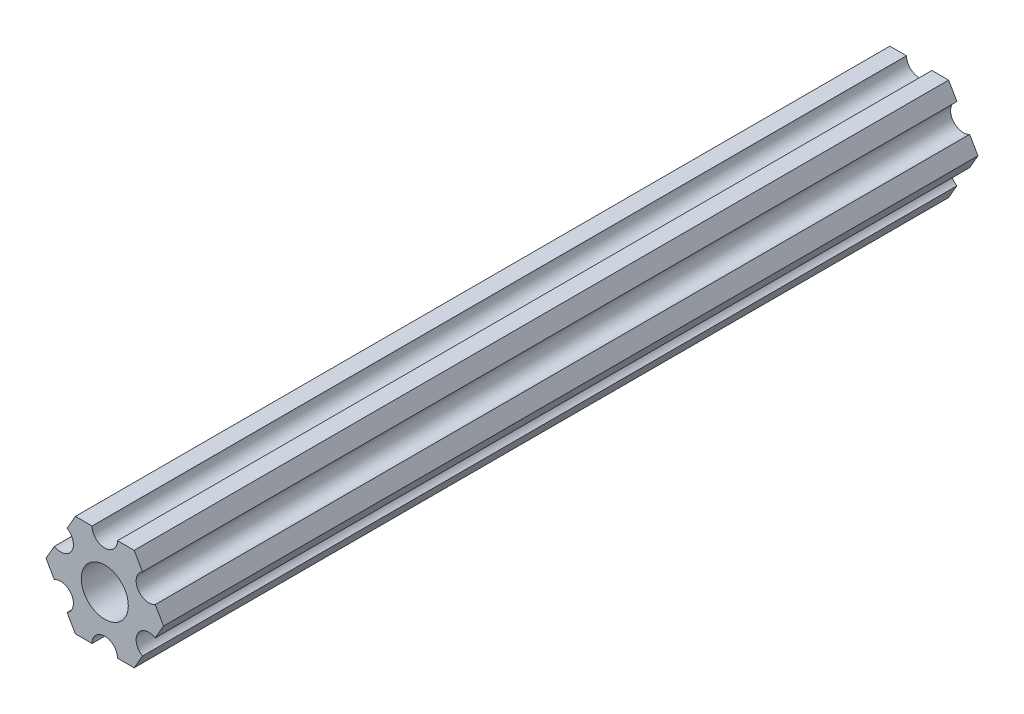
from build123d import *

# Parameters (mm, degrees)
SKETCH1_R           = 2.9337
BOSS_EXTRUDE1_DEPTH = 101.6


with BuildPart() as part:
    # Sketch1 → Boss-Extrude1 (new body)
    with BuildSketch(Plane.XY):
        with BuildLine():
            Line((-1.587500385, 6.349999904), (-3.666174594, 6.349999778))
            Line((-3.666174594, 6.349999778), (-4.70551159, 4.549815043))
            ThreePointArc((-4.70551159, 4.549815043), (-4.12444613, 2.38124975), (-6.293011423, 1.80018429))
            Line((-6.293011423, 1.80018429), (-7.332348419, -4.44e-07))
            Line((-7.332348419, -4.44e-07), (-6.293011205, -1.800185053))
            ThreePointArc((-6.293011205, -1.800185053), (-4.124445841, -2.38125025), (-4.705511038, -4.549815614))
            Line((-4.705511038, -4.549815614), (-3.666173825, -6.350000222))
            Line((-3.666173825, -6.350000222), (-1.587499615, -6.350000096))
            ThreePointArc((-1.587499615, -6.350000096), (2.89e-07, -4.7625), (1.587500385, -6.349999904))
            Line((1.587500385, -6.349999904), (3.666174594, -6.349999778))
            Line((3.666174594, -6.349999778), (4.70551159, -4.549815043))
            ThreePointArc((4.70551159, -4.549815043), (4.12444613, -2.38124975), (6.293011423, -1.80018429))
            Line((6.293011423, -1.80018429), (7.332348419, 4.44e-07))
            Line((7.332348419, 4.44e-07), (6.293011205, 1.800185053))
            ThreePointArc((6.293011205, 1.800185053), (4.124445841, 2.38125025), (4.705511038, 4.549815614))
            Line((4.705511038, 4.549815614), (3.666173825, 6.350000222))
            Line((3.666173825, 6.350000222), (1.587499615, 6.350000096))
            ThreePointArc((1.587499615, 6.350000096), (-2.89e-07, 4.7625), (-1.587500385, 6.349999904))
        make_face()
        Circle(SKETCH1_R, mode=Mode.SUBTRACT)
    extrude(amount=BOSS_EXTRUDE1_DEPTH)


solid = part.part
